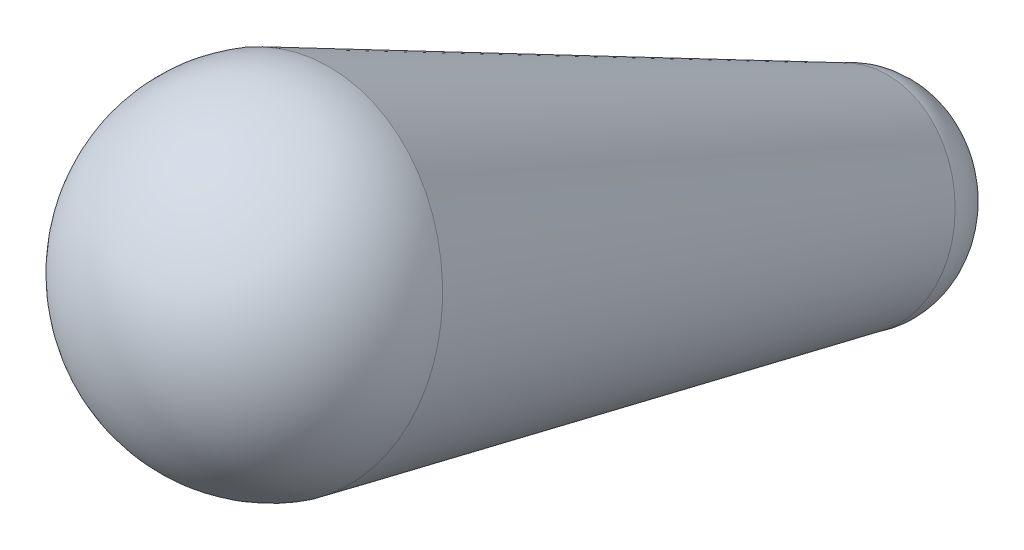
from build123d import *

# Parameters (mm, degrees)
SKETCH1_R           = 6.268898587
BOSS_EXTRUDE1_DEPTH = 24.185697
BOSS_EXTRUDE1_TAPER = 6
DOME1_FACE_RADIUS   = 6.268898587
DOME1_HEIGHT        = 6
DOME2_FACE_RADIUS   = 3.726879399
DOME2_HEIGHT        = 3


with BuildPart() as part:
    # Sketch1 → Boss-Extrude1 (new body)
    with BuildSketch(Plane(origin=(0, -51.695936183, -189.321050655), x_dir=(-1, 0, 0), z_dir=(0, -0.3604986676689615, -0.9327597282306435))):
        Circle(SKETCH1_R)
    extrude(amount=BOSS_EXTRUDE1_DEPTH, taper=BOSS_EXTRUDE1_TAPER)

    # Dome1: an elliptical dome of height H over a round flat face of radius A is half a spheroid: the quarter ellipse of half axes A and H revolved about the face's axis
    with BuildSketch(Plane((0, -51.695936183, -189.321050655), x_dir=(0, 0.9327597282306769, -0.3604986676688751), z_dir=(1, 0, 0)), mode=Mode.PRIVATE) as dome1_quarter:
        Ellipse(DOME1_FACE_RADIUS, DOME1_HEIGHT)
        Rectangle(DOME1_FACE_RADIUS, DOME1_HEIGHT, align=(Align.MIN, Align.MIN), mode=Mode.INTERSECT)
    revolve(dome1_quarter.sketch, axis=Axis((0, -51.695936183, -189.321050655), (0, 0.360498667669, 0.932759728231)))

    # Dome2: an elliptical dome of height H over a round flat face of radius A is half a spheroid: the quarter ellipse of half axes A and H revolved about the face's axis
    with BuildSketch(Plane((0, -60.414847728, -211.880494816), x_dir=(0, -0.9327597282306769, 0.3604986676688751), z_dir=(1, 0, 0)), mode=Mode.PRIVATE) as dome2_quarter:
        Ellipse(DOME2_FACE_RADIUS, DOME2_HEIGHT)
        Rectangle(DOME2_FACE_RADIUS, DOME2_HEIGHT, align=(Align.MIN, Align.MIN), mode=Mode.INTERSECT)
    revolve(dome2_quarter.sketch, axis=Axis((0, -60.414847728, -211.880494816), (0, -0.360498667669, -0.932759728231)))


solid = part.part
